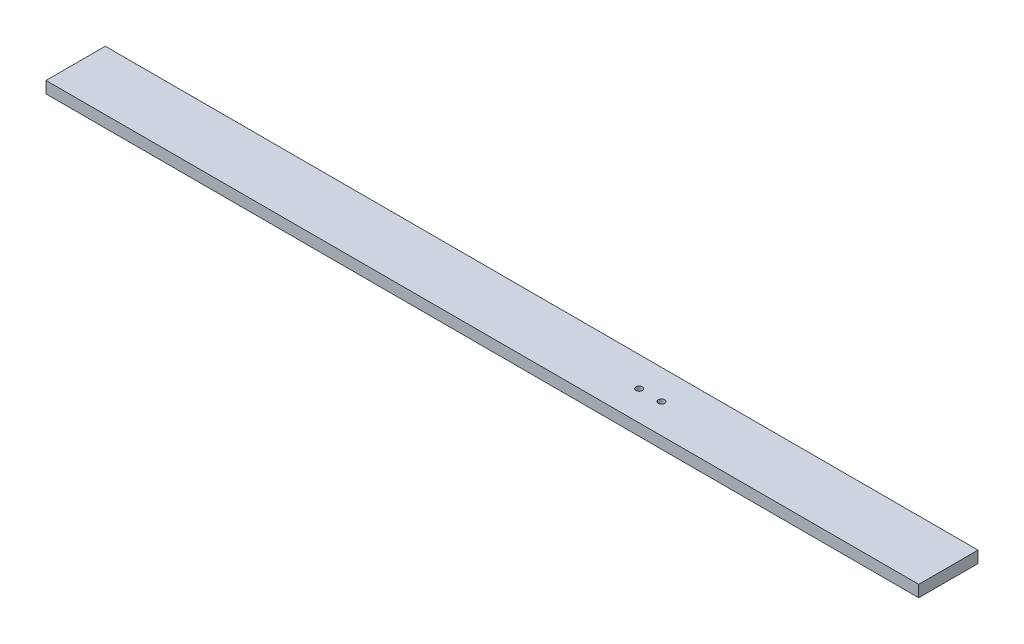
from build123d import *

# Parameters (mm, degrees)
CROQUIS1_W              = 748
CROQUIS1_H              = 50.8
SALIENTE_EXTRUIR1_DEPTH = 10
CROQUIS2_R              = 2.75
CORTAR_EXTRUIR1_DEPTH   = 11


with BuildPart() as part:
    # Croquis1 → Saliente-Extruir1 (new body)
    with BuildSketch(Plane(origin=(0, 0, 0), x_dir=(1, 0, 0), z_dir=(0, 1, 0))):
        Rectangle(CROQUIS1_W, CROQUIS1_H)
    extrude(amount=SALIENTE_EXTRUIR1_DEPTH)

    # Croquis2 → Cortar-Extruir1 (cut, through all)
    with BuildSketch(Plane(origin=(0, 10, 0), x_dir=(1, 0, 0), z_dir=(0, 1, 0))):
        with Locations((128.1, 0)):
            Circle(CROQUIS2_R)
        with Locations((109, 0)):
            Circle(CROQUIS2_R)
    extrude(amount=-CORTAR_EXTRUIR1_DEPTH, mode=Mode.SUBTRACT)


solid = part.part
